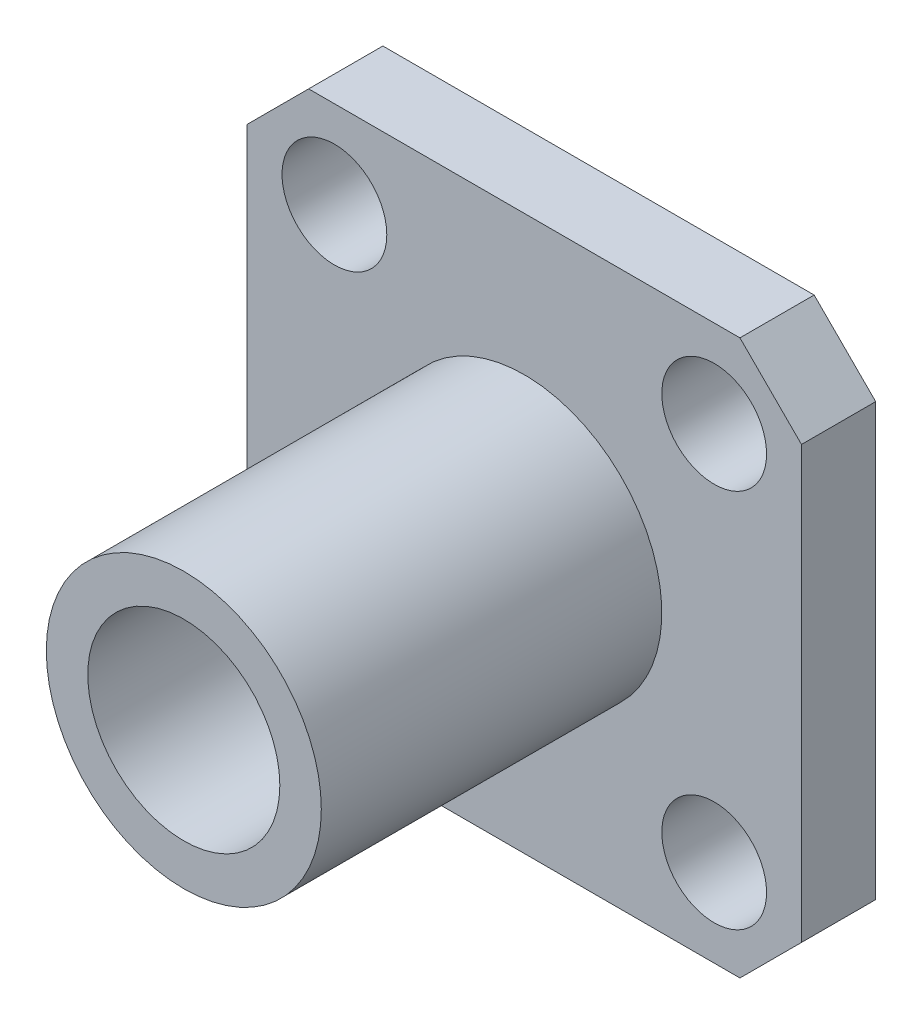
from build123d import *

# Parameters (mm, degrees)
SKETCH1_W           = 12.7
SKETCH1_H           = 12.7
BOSS_EXTRUDE1_DEPTH = 1.7
CHAMFER3_SIZE       = 1.41
SKETCH2_R           = 1.2
CUT_EXTRUDE2_DEPTH  = 2.7
SKETCH3_R           = 3.15
SKETCH3_R_2         = 2.2
BOSS_EXTRUDE2_DEPTH = 7.8
SKETCH4_R           = 0.64
BOSS_EXTRUDE3_DEPTH = 5


with BuildPart() as part:
    # Sketch1 → Boss-Extrude1 (new body)
    with BuildSketch(Plane(origin=(0, 0, 0), x_dir=(0, 1, 0), z_dir=(0, 0, 1))):
        Rectangle(SKETCH1_W, SKETCH1_H)
    extrude(amount=BOSS_EXTRUDE1_DEPTH)

    # Chamfer3
    chamfer3_edges = [part.edges().sort_by_distance(p)[0] for p in [
        (6.35, 6.35, 0.85),
        (6.35, -6.35, 0.85),
        (-6.35, -6.35, 0.85),
        (-6.35, 6.35, 0.85),
    ]]
    chamfer(chamfer3_edges, length=CHAMFER3_SIZE)

    # Sketch2 → Cut-Extrude2 (cut, through all)
    with BuildSketch(Plane.XY.offset(1.7)):
        with Locations((-4.35, 4.35)):
            Circle(SKETCH2_R)
        with Locations((-4.35, -4.35)):
            Circle(SKETCH2_R)
        with Locations((4.35, -4.35)):
            Circle(SKETCH2_R)
        with Locations((4.35, 4.35)):
            Circle(SKETCH2_R)
    extrude(amount=-CUT_EXTRUDE2_DEPTH, mode=Mode.SUBTRACT)

    # Sketch3 → Boss-Extrude2 (add)
    with BuildSketch(Plane.XY.offset(1.7)):
        Circle(SKETCH3_R)
        Circle(SKETCH3_R_2, mode=Mode.SUBTRACT)
    extrude(amount=BOSS_EXTRUDE2_DEPTH)

    # Sketch4 → Boss-Extrude3 (add)
    with BuildSketch(Plane(origin=(0, 0, 0), x_dir=(1, 0, 0), z_dir=(0, 0, -1))):
        Circle(SKETCH4_R)
    extrude(amount=BOSS_EXTRUDE3_DEPTH)


solid = part.part
